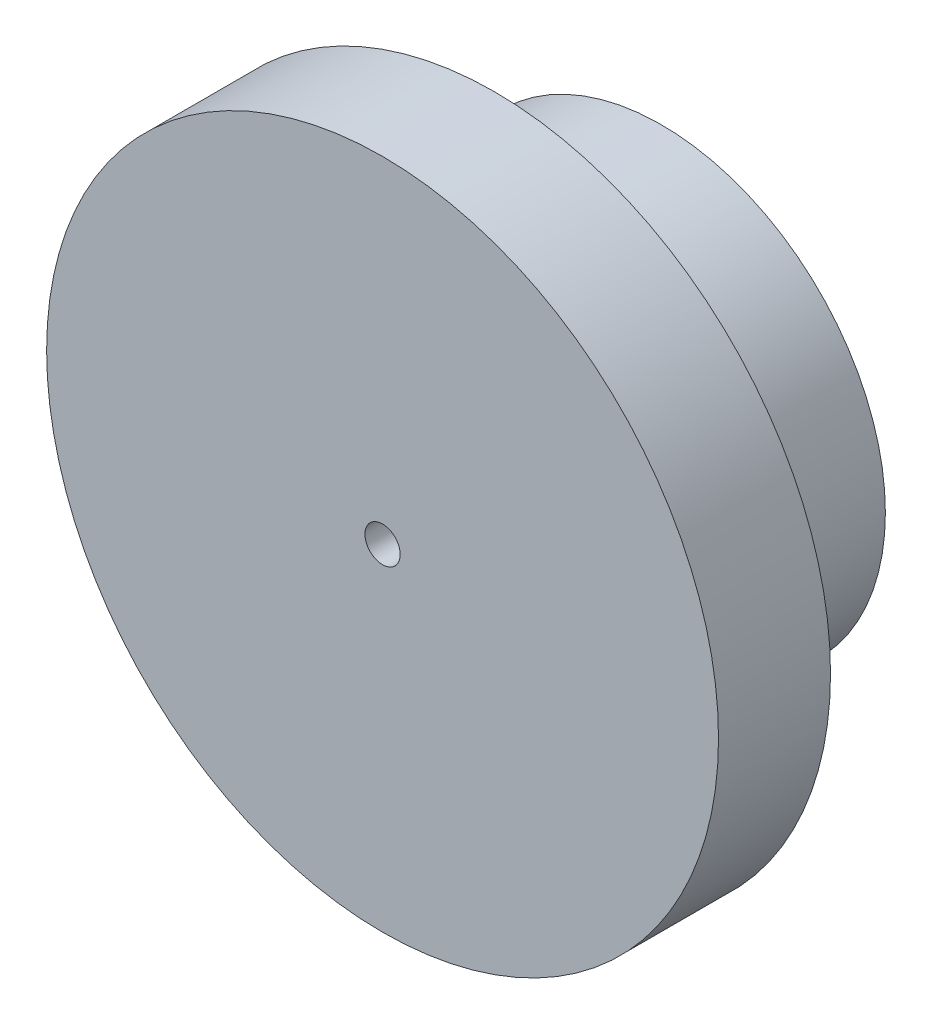
from build123d import *

# Parameters (mm, degrees)
SKETCH2_R                = 12.7
BOSS_EXTRUDE1_DEPTH      = 6.35
BOSS_EXTRUDE1_DEPTH_BACK = 3.1115
SKETCH4_R                = 19.05
SKETCH4_R_2              = 1
BOSS_EXTRUDE2_DEPTH      = 6.35
SKETCH5_R                = 11
CUT_EXTRUDE1_DEPTH       = 7


with BuildPart() as part:
    # Sketch2 → Boss-Extrude1 (new body, two sides)
    with BuildSketch(Plane.XY) as boss_extrude1_sk:
        Circle(SKETCH2_R)
    extrude(amount=BOSS_EXTRUDE1_DEPTH)
    extrude(boss_extrude1_sk.sketch, amount=-BOSS_EXTRUDE1_DEPTH_BACK)

    # Sketch4 → Boss-Extrude2 (add)
    with BuildSketch(Plane.XY.offset(6.35)):
        Circle(SKETCH4_R)
        Circle(SKETCH4_R_2, mode=Mode.SUBTRACT)
    extrude(amount=BOSS_EXTRUDE2_DEPTH)

    # Sketch5 → Cut-Extrude1 (cut)
    with BuildSketch(Plane(origin=(0, 0, -3.1115), x_dir=(-1, 0, 0), z_dir=(0, 0, -1))):
        Circle(SKETCH5_R)
    extrude(amount=-CUT_EXTRUDE1_DEPTH, mode=Mode.SUBTRACT)


solid = part.part
